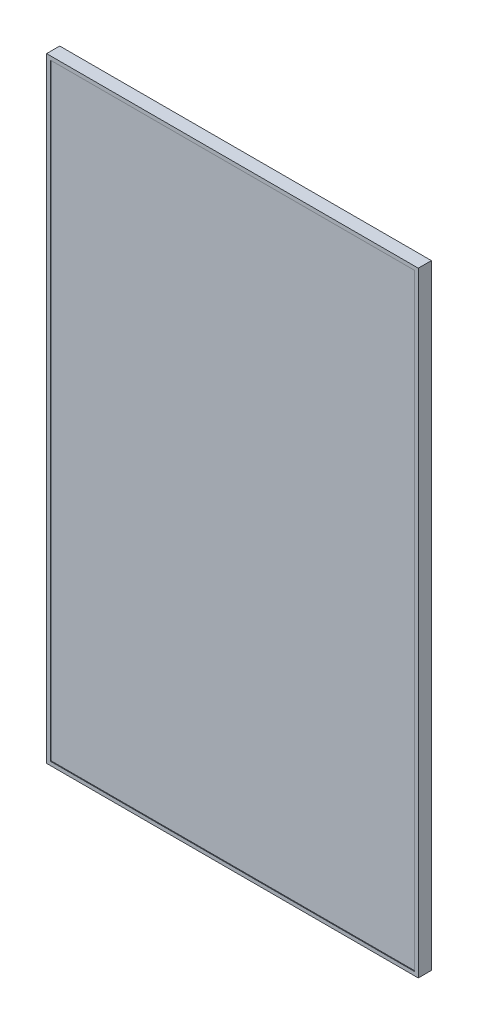
from build123d import *

# Parameters (mm, degrees)
CROQUIS1_W              = 991
CROQUIS1_H              = 1639
SALIENTE_EXTRUIR1_DEPTH = 5
CROQUIS2_W              = 971
CROQUIS2_H              = 1619
CORTAR_EXTRUIR1_DEPTH   = 2
CROQUIS3_W              = 991
CROQUIS3_H              = 1639
CROQUIS3_W_2            = 989
CROQUIS3_H_2            = 1637
SALIENTE_EXTRUIR2_DEPTH = 30
CROQUIS4_W              = 991
CROQUIS4_H              = 1639
CROQUIS4_W_2            = 921
CROQUIS4_H_2            = 1569
SALIENTE_EXTRUIR3_DEPTH = 1
CROQUIS5_R              = 2.5
CORTAR_EXTRUIR2_DEPTH   = 1


with BuildPart() as part:
    # Croquis1 → Saliente-Extruir1 (new body)
    with BuildSketch(Plane.XY):
        Rectangle(CROQUIS1_W, CROQUIS1_H)
    extrude(amount=SALIENTE_EXTRUIR1_DEPTH)

    # Croquis2 → Cortar-Extruir1 (cut)
    with BuildSketch(Plane.XY.offset(5)):
        Rectangle(CROQUIS2_W, CROQUIS2_H)
    extrude(amount=-CORTAR_EXTRUIR1_DEPTH, mode=Mode.SUBTRACT)

    # Croquis3 → Saliente-Extruir2 (add)
    with BuildSketch(Plane(origin=(0, 0, 0), x_dir=(-1, 0, 0), z_dir=(0, 0, -1))):
        Rectangle(CROQUIS3_W, CROQUIS3_H)
        Rectangle(CROQUIS3_W_2, CROQUIS3_H_2, mode=Mode.SUBTRACT)
    extrude(amount=SALIENTE_EXTRUIR2_DEPTH)

    # Croquis4 → Saliente-Extruir3 (add)
    with BuildSketch(Plane(origin=(0, 0, -30), x_dir=(-1, 0, 0), z_dir=(0, 0, -1))):
        Rectangle(CROQUIS4_W, CROQUIS4_H)
        Rectangle(CROQUIS4_W_2, CROQUIS4_H_2, mode=Mode.SUBTRACT)
    extrude(amount=-SALIENTE_EXTRUIR3_DEPTH)

    # Croquis5 → Cortar-Extruir2 (cut)
    with BuildSketch(Plane(origin=(0, 0, -30), x_dir=(-1, 0, 0), z_dir=(0, 0, -1))):
        with Locations((-478, 0)):
            Circle(CROQUIS5_R)
        with Locations((478, 0)):
            Circle(CROQUIS5_R)
        with BuildLine():
            Line((-473, 652.5), (-473, 648.5))
            ThreePointArc((-473, 648.5), (-478, 643.5), (-483, 648.5))
            Line((-483, 648.5), (-483, 652.5))
            ThreePointArc((-483, 652.5), (-478, 657.5), (-473, 652.5))
        make_face()
        with BuildLine():
            Line((-473, 398.5), (-473, 402.5))
            ThreePointArc((-473, 402.5), (-478, 407.5), (-483, 402.5))
            Line((-483, 402.5), (-483, 398.5))
            ThreePointArc((-483, 398.5), (-478, 393.5), (-473, 398.5))
        make_face()
        with BuildLine():
            Line((-473, -652.5), (-473, -648.5))
            ThreePointArc((-473, -648.5), (-478, -643.5), (-483, -648.5))
            Line((-483, -648.5), (-483, -652.5))
            ThreePointArc((-483, -652.5), (-478, -657.5), (-473, -652.5))
        make_face()
        with BuildLine():
            Line((-473, -398.5), (-473, -402.5))
            ThreePointArc((-473, -402.5), (-478, -407.5), (-483, -402.5))
            Line((-483, -402.5), (-483, -398.5))
            ThreePointArc((-483, -398.5), (-478, -393.5), (-473, -398.5))
        make_face()
        with BuildLine():
            Line((473, -652.5), (473, -648.5))
            ThreePointArc((473, -648.5), (478, -643.5), (483, -648.5))
            Line((483, -648.5), (483, -652.5))
            ThreePointArc((483, -652.5), (478, -657.5), (473, -652.5))
        make_face()
        with BuildLine():
            Line((473, -398.5), (473, -402.5))
            ThreePointArc((473, -402.5), (478, -407.5), (483, -402.5))
            Line((483, -402.5), (483, -398.5))
            ThreePointArc((483, -398.5), (478, -393.5), (473, -398.5))
        make_face()
        with BuildLine():
            Line((473, 398.5), (473, 402.5))
            ThreePointArc((473, 402.5), (478, 407.5), (483, 402.5))
            Line((483, 402.5), (483, 398.5))
            ThreePointArc((483, 398.5), (478, 393.5), (473, 398.5))
        make_face()
        with BuildLine():
            Line((473, 652.5), (473, 648.5))
            ThreePointArc((473, 648.5), (478, 643.5), (483, 648.5))
            Line((483, 648.5), (483, 652.5))
            ThreePointArc((483, 652.5), (478, 657.5), (473, 652.5))
        make_face()
    extrude(amount=-CORTAR_EXTRUIR2_DEPTH, mode=Mode.SUBTRACT)


solid = part.part
